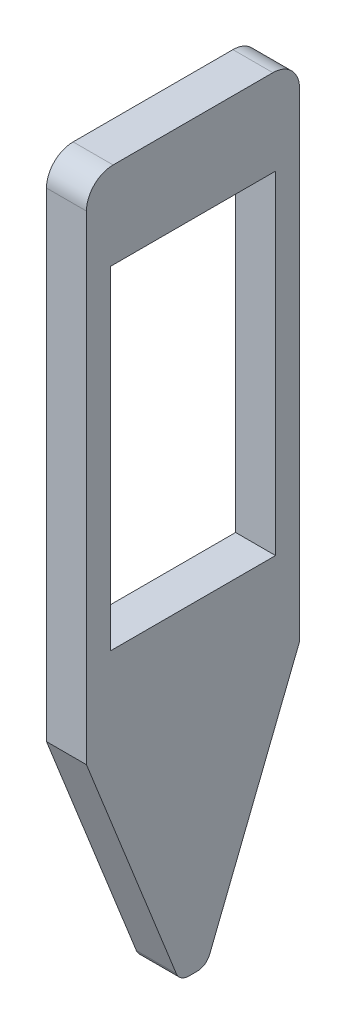
from build123d import *

# Parameters (mm, degrees)
ESBO_O1_W                = 12.4
ESBO_O1_H                = 25
RESSALTO_EXTRUS_O1_DEPTH = 3
FILETE1_R                = 2


with BuildPart() as part:
    # Esboço1 → Ressalto-extrusão1 (new body)
    with BuildSketch(Plane(origin=(0, 0, 0), x_dir=(0, 0, -1), z_dir=(1, 0, 0))):
        with BuildLine():
            Line((-8, 19), (8, 19))
            Line((8, 19), (8, -19))
            Line((8, -19), (1.25078293, -35.963499669))
            ThreePointArc((1.25078293, -35.963499669), (0.883014852, -36.421369201), (0.321624406, -36.593818135))
            Line((0.321624406, -36.593818135), (-0.321624406, -36.593818135))
            ThreePointArc((-0.321624406, -36.593818135), (-0.883014852, -36.421369201), (-1.25078293, -35.963499669))
            Line((-1.25078293, -35.963499669), (-8, -19))
            Line((-8, -19), (-8, 19))
        make_face()
        Rectangle(ESBO_O1_W, ESBO_O1_H, mode=Mode.SUBTRACT)
    extrude(amount=RESSALTO_EXTRUS_O1_DEPTH)

    # Filete1
    filete1_edges = [part.edges().sort_by_distance(p)[0] for p in [
        (1.5, 19, 8),
        (1.5, 19, -8),
    ]]
    fillet(filete1_edges, radius=FILETE1_R)


solid = part.part
